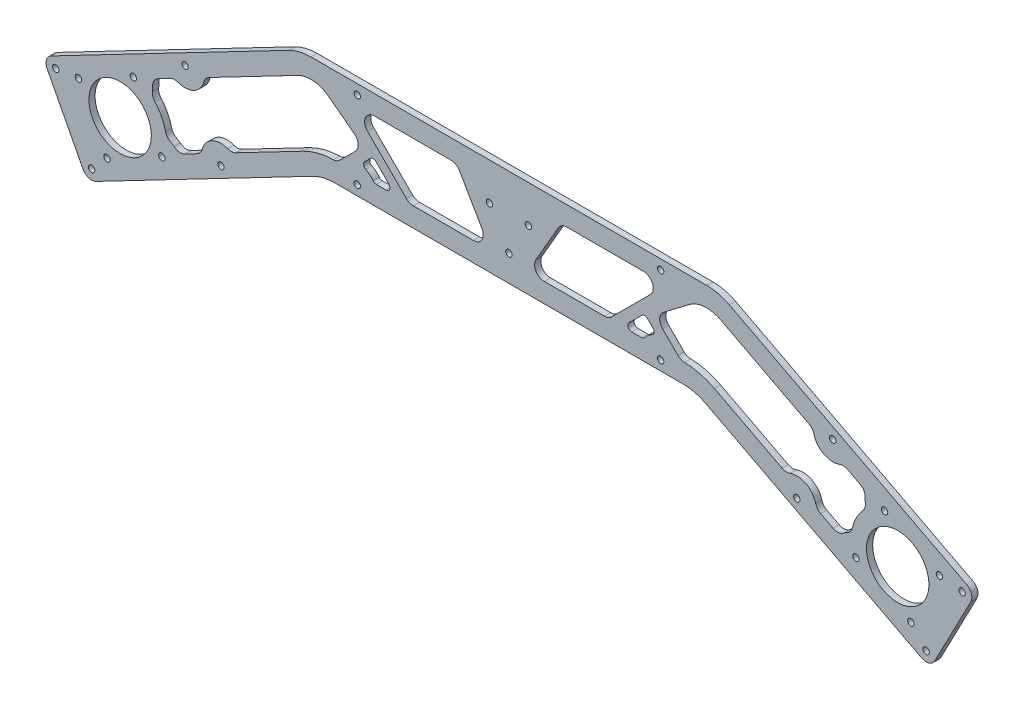
from build123d import *

# Parameters (mm, degrees)
SKETCH1_R              = 16.05
SKETCH1_R_2            = 1.65
BASE_DEPTH             = 3.175
SKETCH3_R              = 1.65
STRUT_HOLES_DEPTH      = 4.175
LIGHTENING_HOLES_DEPTH = 4.175


with BuildPart() as part:
    # Sketch1 → Base (new body)
    with BuildSketch(Plane.XY):
        with BuildLine():
            Line((-113.35576806, -30.824729171), (-235.437134887, -94.376266227))
            ThreePointArc((-235.437134887, -94.376266227), (-237.896976574, -97.307791395), (-237.563445987, -101.120063459))
            Line((-237.563445987, -101.120063459), (-219.093501457, -136.600496786))
            ThreePointArc((-219.093501457, -136.600496786), (-216.161976289, -139.060338474), (-212.349704225, -138.726807886))
            Line((-212.349704225, -138.726807886), (-101.120845899, -80.824729171))
            ThreePointArc((-101.120845899, -80.824729171), (-95.519277876, -78.716448255), (-89.577130568, -78))
            Line((-89.577130568, -78), (89.577130568, -78))
            ThreePointArc((89.577130568, -78), (95.519277876, -78.716448255), (101.120845899, -80.824729171))
            Line((101.120845899, -80.824729171), (212.349704225, -138.726807886))
            ThreePointArc((212.349704225, -138.726807886), (216.161976289, -139.060338474), (219.093501457, -136.600496786))
            Line((219.093501457, -136.600496786), (237.563445987, -101.120063459))
            ThreePointArc((237.563445987, -101.120063459), (237.896976574, -97.307791395), (235.437134887, -94.376266227))
            Line((235.437134887, -94.376266227), (113.35576806, -30.824729171))
            ThreePointArc((113.35576806, -30.824729171), (107.754200038, -28.716448255), (101.812052729, -28))
            Line((101.812052729, -28), (-101.812052729, -28))
            ThreePointArc((-101.812052729, -28), (-107.754200038, -28.716448255), (-113.35576806, -30.824729171))
        make_face()
        with Locations((-200, -104.11341011)):
            Circle(SKETCH1_R, mode=Mode.SUBTRACT)
        with Locations((-221.458631392, -97.347529622)):
            Circle(SKETCH1_R_2, mode=Mode.SUBTRACT)
        with Locations((-193.234119511, -82.654778719)):
            Circle(SKETCH1_R_2, mode=Mode.SUBTRACT)
        with Locations((-178.541368608, -110.879290599)):
            Circle(SKETCH1_R_2, mode=Mode.SUBTRACT)
        with Locations((-206.765880489, -125.572041502)):
            Circle(SKETCH1_R_2, mode=Mode.SUBTRACT)
        with Locations((206.765880489, -125.572041502)):
            Circle(SKETCH1_R_2, mode=Mode.SUBTRACT)
        with Locations((221.458631392, -97.347529622)):
            Circle(SKETCH1_R_2, mode=Mode.SUBTRACT)
        with Locations((193.234119511, -82.654778719)):
            Circle(SKETCH1_R_2, mode=Mode.SUBTRACT)
        with Locations((178.541368608, -110.879290599)):
            Circle(SKETCH1_R_2, mode=Mode.SUBTRACT)
        with Locations((200, -104.11341011)):
            Circle(SKETCH1_R, mode=Mode.SUBTRACT)
        with Locations((-10, -47.226497308)):
            Circle(SKETCH1_R_2, mode=Mode.SUBTRACT)
        with Locations((10, -47.226497308)):
            Circle(SKETCH1_R_2, mode=Mode.SUBTRACT)
        with Locations((0, -64.547005384)):
            Circle(SKETCH1_R_2, mode=Mode.SUBTRACT)
    extrude(amount=BASE_DEPTH)

    # Sketch3 → Strut Holes (cut, through all)
    with BuildSketch(Plane.XY.offset(3.175)):
        with Locations((-214.658447291, -134.29175372)):
            Circle(SKETCH3_R)
        with Locations((-148.132634803, -99.660607727)):
            Circle(SKETCH3_R)
        with Locations((-78.03119405, -73)):
            Circle(SKETCH3_R)
        with Locations((-78.03119405, -33)):
            Circle(SKETCH3_R)
        with Locations((-166.602579332, -64.1801744)):
            Circle(SKETCH3_R)
        with Locations((-233.128391821, -98.811320393)):
            Circle(SKETCH3_R)
        with Locations((233.128391821, -98.811320393)):
            Circle(SKETCH3_R)
        with Locations((166.602579332, -64.1801744)):
            Circle(SKETCH3_R)
        with Locations((78.03119405, -33)):
            Circle(SKETCH3_R)
        with Locations((78.03119405, -73)):
            Circle(SKETCH3_R)
        with Locations((148.132634803, -99.660607727)):
            Circle(SKETCH3_R)
        with Locations((214.658447291, -134.29175372)):
            Circle(SKETCH3_R)
    extrude(amount=-STRUT_HOLES_DEPTH, mode=Mode.SUBTRACT)

    # Sketch4 → Lightening Holes (cut, through all)
    with BuildSketch(Plane(origin=(0, 0, 0), x_dir=(-1, 0, 0), z_dir=(0, 0, -1))):
        with BuildLine():
            Line((-166.732564066, -103.70620831), (-160.358460468, -100.38806))
            ThreePointArc((-160.358460468, -100.38806), (-158.749015825, -99.059097441), (-157.82234729, -97.188873132))
            ThreePointArc((-157.82234729, -97.188873132), (-152.750120935, -90.790499395), (-144.599570492, -90.305531214))
            ThreePointArc((-144.599570492, -90.305531214), (-142.53605719, -90.619165384), (-140.52429527, -90.063047123))
            Line((-140.52429527, -90.063047123), (-105.738332031, -71.954620839))
            ThreePointArc((-105.738332031, -71.954620839), (-98.269905543, -69.096671797), (-90.347714306, -68.008483875))
            ThreePointArc((-90.347714306, -68.008483875), (-88.493641512, -67.607748759), (-86.922263791, -66.545229763))
            Line((-86.922263791, -66.545229763), (-79.009491694, -58.632457666))
            ThreePointArc((-79.009491694, -58.632457666), (-77.556385787, -54.760066484), (-79.516892411, -51.11817906))
            Line((-79.516892411, -51.11817906), (-92.727653164, -41.063765898))
            ThreePointArc((-92.727653164, -41.063765898), (-100.534196684, -38.054529652), (-108.738281928, -39.694837502))
            Line((-108.738281928, -39.694837502), (-154.376753667, -63.452722127))
            ThreePointArc((-154.376753667, -63.452722127), (-155.986198311, -64.781684686), (-156.912866845, -66.651908996))
            ThreePointArc((-156.912866845, -66.651908996), (-161.9850932, -73.050282732), (-170.135643643, -73.535250914))
            ThreePointArc((-170.135643643, -73.535250914), (-172.199156946, -73.221616743), (-174.210918865, -73.777735004))
            Line((-174.210918865, -73.777735004), (-180.585022463, -77.095883315))
            ThreePointArc((-180.585022463, -77.095883315), (-182.645072259, -79.099137955), (-183.262226102, -81.905551227))
            ThreePointArc((-183.262226102, -81.905551227), (-183.239750678, -82.990325484), (-183.334932996, -84.071149549))
            ThreePointArc((-183.334932996, -84.071149549), (-183.171057415, -86.227404823), (-182.1120053, -88.112796196))
            ThreePointArc((-182.1120053, -88.112796196), (-178.711740004, -93.031443393), (-176.632932149, -98.637997792))
            ThreePointArc((-176.632932149, -98.637997792), (-175.695957289, -100.586938562), (-174.023651545, -101.957954795))
            ThreePointArc((-174.023651545, -101.957954795), (-173.083697968, -102.499921221), (-172.207994291, -103.140532962))
            ThreePointArc((-172.207994291, -103.140532962), (-169.555130221, -104.244682653), (-166.732564066, -103.70620831))
        make_face()
        with BuildLine():
            Line((-68.284399705, -68), (-63.199367137, -68))
            ThreePointArc((-63.199367137, -68), (-61.351608072, -66.765366865), (-61.785153575, -64.585786438))
            Line((-61.785153575, -64.585786438), (-68.424239552, -57.946700461))
            ThreePointArc((-68.424239552, -57.946700461), (-69.838453114, -57.360914023), (-71.252666676, -57.946700461))
            Line((-71.252666676, -57.946700461), (-74.132142401, -60.826176185))
            ThreePointArc((-74.132142401, -60.826176185), (-74.691303243, -62.565648815), (-73.60347304, -64.033658123))
            ThreePointArc((-73.60347304, -64.033658123), (-71.563592326, -65.373065627), (-69.908865429, -67.166666667))
            ThreePointArc((-69.908865429, -67.166666667), (-69.197270634, -67.779513042), (-68.284399705, -68))
        make_face()
        with BuildLine():
            Line((-25.430550415, -40.5), (-13.883545032, -60.5))
            ThreePointArc((-13.883545032, -60.5), (-13.883545032, -65.5), (-18.21367205, -68))
            Line((-18.21367205, -68), (-49.228804389, -68))
            ThreePointArc((-49.228804389, -68), (-51.14222155, -67.619397663), (-52.764338294, -66.535533906))
            Line((-52.764338294, -66.535533906), (-72.764338294, -46.535533906))
            ThreePointArc((-72.764338294, -46.535533906), (-73.848202051, -41.086582838), (-69.228804389, -38))
            Line((-69.228804389, -38), (-29.760677434, -38))
            ThreePointArc((-29.760677434, -38), (-27.260677434, -38.669872981), (-25.430550415, -40.5))
        make_face()
        with BuildLine():
            Line((52.764338294, -66.535533906), (72.764338294, -46.535533906))
            ThreePointArc((72.764338294, -46.535533906), (73.848202051, -41.086582838), (69.228804389, -38))
            Line((69.228804389, -38), (29.760677434, -38))
            ThreePointArc((29.760677434, -38), (27.260677434, -38.669872981), (25.430550415, -40.5))
            Line((25.430550415, -40.5), (13.883545032, -60.5))
            ThreePointArc((13.883545032, -60.5), (13.883545032, -65.5), (18.21367205, -68))
            Line((18.21367205, -68), (49.228804389, -68))
            ThreePointArc((49.228804389, -68), (51.14222155, -67.619397663), (52.764338294, -66.535533906))
        make_face()
        with BuildLine():
            Line((68.284399705, -68), (63.199367137, -68))
            ThreePointArc((63.199367137, -68), (61.351608072, -66.765366865), (61.785153575, -64.585786438))
            Line((61.785153575, -64.585786438), (68.424239552, -57.946700461))
            ThreePointArc((68.424239552, -57.946700461), (69.838453114, -57.360914023), (71.252666676, -57.946700461))
            Line((71.252666676, -57.946700461), (74.132142401, -60.826176185))
            ThreePointArc((74.132142401, -60.826176185), (74.691303243, -62.565648815), (73.60347304, -64.033658123))
            ThreePointArc((73.60347304, -64.033658123), (71.563592326, -65.373065627), (69.908865429, -67.166666667))
            ThreePointArc((69.908865429, -67.166666667), (69.197270634, -67.779513042), (68.284399705, -68))
        make_face()
        with BuildLine():
            Line((154.376753667, -63.452722127), (108.738281928, -39.694837502))
            ThreePointArc((108.738281928, -39.694837502), (100.534196684, -38.054529652), (92.727653164, -41.063765898))
            Line((92.727653164, -41.063765898), (79.516892411, -51.11817906))
            ThreePointArc((79.516892411, -51.11817906), (77.556385787, -54.760066484), (79.009491694, -58.632457666))
            Line((79.009491694, -58.632457666), (86.922263791, -66.545229763))
            ThreePointArc((86.922263791, -66.545229763), (88.493641512, -67.607748759), (90.347714306, -68.008483875))
            ThreePointArc((90.347714306, -68.008483875), (98.269905543, -69.096671797), (105.738332031, -71.954620839))
            Line((105.738332031, -71.954620839), (140.52429527, -90.063047123))
            ThreePointArc((140.52429527, -90.063047123), (142.53605719, -90.619165384), (144.599570492, -90.305531214))
            ThreePointArc((144.599570492, -90.305531214), (152.750120935, -90.790499395), (157.82234729, -97.188873132))
            ThreePointArc((157.82234729, -97.188873132), (158.749015825, -99.059097441), (160.358460468, -100.38806))
            Line((160.358460468, -100.38806), (166.732564066, -103.70620831))
            ThreePointArc((166.732564066, -103.70620831), (169.555130221, -104.244682653), (172.207994291, -103.140532962))
            ThreePointArc((172.207994291, -103.140532962), (173.083697968, -102.499921221), (174.023651545, -101.957954795))
            ThreePointArc((174.023651545, -101.957954795), (175.695957289, -100.586938562), (176.632932149, -98.637997792))
            ThreePointArc((176.632932149, -98.637997792), (178.711740004, -93.031443393), (182.1120053, -88.112796196))
            ThreePointArc((182.1120053, -88.112796196), (183.171057415, -86.227404823), (183.334932996, -84.071149549))
            ThreePointArc((183.334932996, -84.071149549), (183.239750678, -82.990325484), (183.262226102, -81.905551227))
            ThreePointArc((183.262226102, -81.905551227), (182.645072259, -79.099137955), (180.585022463, -77.095883315))
            Line((180.585022463, -77.095883315), (174.210918865, -73.777735004))
            ThreePointArc((174.210918865, -73.777735004), (172.199156946, -73.221616743), (170.135643643, -73.535250914))
            ThreePointArc((170.135643643, -73.535250914), (161.9850932, -73.050282732), (156.912866845, -66.651908996))
            ThreePointArc((156.912866845, -66.651908996), (155.986198311, -64.781684686), (154.376753667, -63.452722127))
        make_face()
    extrude(amount=-LIGHTENING_HOLES_DEPTH, mode=Mode.SUBTRACT)


solid = part.part
